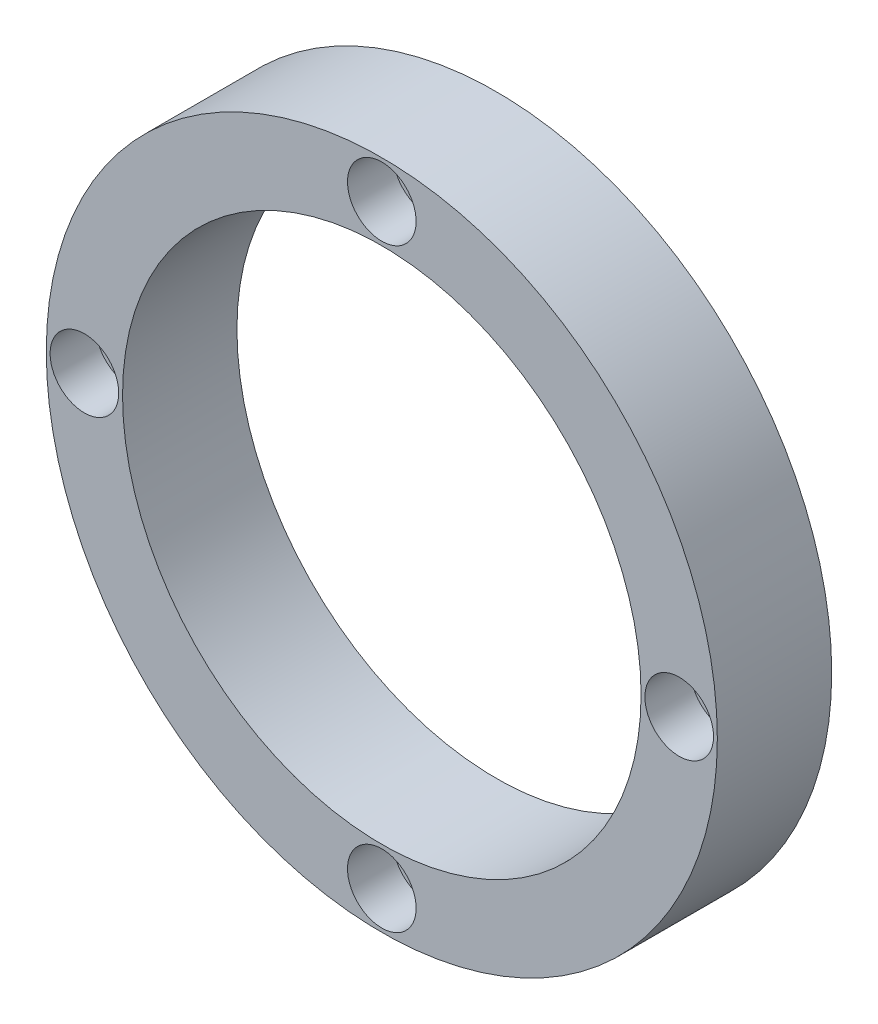
from build123d import *

# Parameters (mm, degrees)
SKETCH_1_R               = 44
SKETCH_1_R_2             = 34
EXTRUDE_1_DEPTH          = 15
SKETCH_2_R               = 4.5
CUT_EXTRUDE_1_DEPTH      = 6
SKETCH_3_R               = 2.5
CUT_EXTRUDE_2_DEPTH      = 11
PATTERN_CIRCULAR_1_COUNT = 4


with BuildPart() as part:
    # 草图1 → 凸台-拉伸1 (new body)
    with BuildSketch(Plane.XY):
        Circle(SKETCH_1_R)
        Circle(SKETCH_1_R_2, mode=Mode.SUBTRACT)
    extrude(amount=EXTRUDE_1_DEPTH)

    # 草图2 → 切除-拉伸1 (cut)
    with BuildSketch(Plane.XY.offset(15)):
        with Locations((39, 0)):
            Circle(SKETCH_2_R)
    cut_extrude_1 = extrude(amount=-CUT_EXTRUDE_1_DEPTH, mode=Mode.SUBTRACT)

    # 草图3 → 切除-拉伸2 (cut)
    with BuildSketch(Plane.XY.offset(9)):
        with Locations((39, 0)):
            Circle(SKETCH_3_R)
    cut_extrude_2 = extrude(amount=-CUT_EXTRUDE_2_DEPTH, mode=Mode.SUBTRACT)

    # 阵列(圆周)1: 切除-拉伸1, 切除-拉伸2 ×4 about axis
    pattern_circular_1_axis = Axis((0, 0, 0), (0, 0, 1))
    for i in range(1, PATTERN_CIRCULAR_1_COUNT):
        add(cut_extrude_1.rotate(pattern_circular_1_axis, i * 360 / PATTERN_CIRCULAR_1_COUNT), mode=Mode.SUBTRACT)
        add(cut_extrude_2.rotate(pattern_circular_1_axis, i * 360 / PATTERN_CIRCULAR_1_COUNT), mode=Mode.SUBTRACT)


solid = part.part
